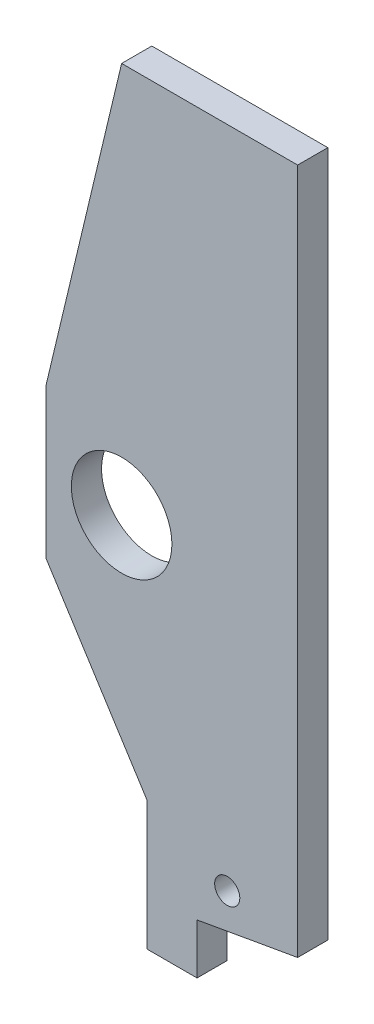
from build123d import *

# Parameters (mm, degrees)
SKETCH1_W           = 10
SKETCH1_H           = 70
BOSS_EXTRUDE1_DEPTH = 3
BOSS_EXTRUDE2_DEPTH = 3
SKETCH3_R           = 5
SKETCH3_R_2         = 1.25
CUT_EXTRUDE1_DEPTH  = 4


with BuildPart() as part:
    # Sketch1 → Boss-Extrude1 (new body)
    with BuildSketch(Plane.XY):
        with Locations((-30.31593178, 0.053868552)):
            Rectangle(SKETCH1_W, SKETCH1_H)
    extrude(amount=BOSS_EXTRUDE1_DEPTH)

    # Sketch2 → Boss-Extrude2 (add)
    with BuildSketch(Plane.XY.offset(3)):
        Polygon((-40.31593178, -39.946131448), (-40.31593178, -27.079464781), (-50.31593178, -11.346131448), (-50.31593178, 3.653868552), (-42.81593178, 35.053868552), (-35.31593178, 35.053868552), (-35.31593178, -34.946131448), (-35.31593178, -39.946131448), align=None)
    extrude(amount=-BOSS_EXTRUDE2_DEPTH)

    # Sketch3 → Cut-Extrude1 (cut, through all)
    with BuildSketch(Plane.XY.offset(3)):
        with Locations((-42.81593178, -3.846131448)):
            Circle(SKETCH3_R)
        with Locations((-32.31593178, -30.946131448)):
            Circle(SKETCH3_R_2)
        Polygon((-35.31593178, -34.946131448), (-25.31593178, -33.182379001), (-25.31593178, -34.946131448), align=None)
    extrude(amount=-CUT_EXTRUDE1_DEPTH, mode=Mode.SUBTRACT)


solid = part.part
